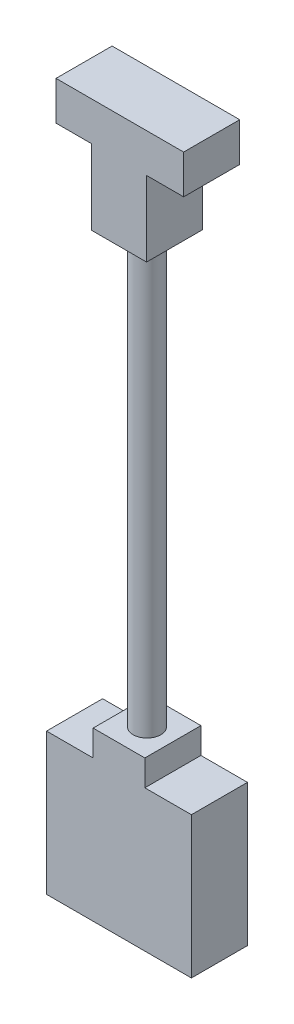
from build123d import *

# Parameters (mm, degrees)
BOSS_EXTRUDE1_DEPTH = 6.5
BOSS_EXTRUDE2_DEPTH = 6.5
SKETCH2_R           = 1.6
BOSS_EXTRUDE3_DEPTH = 55


with BuildPart() as part:
    # Sketch1 → Boss-Extrude1 (new body)
    with BuildSketch(Plane.XY):
        Polygon((9.277156847, 35.75), (13.377156847, 35.75), (13.377156847, 27.05), (19.777156847, 27.05), (19.777156847, 35.75), (24.077156847, 35.75), (24.077156847, 40.25), (9.277156847, 40.25), align=None)
    extrude(amount=BOSS_EXTRUDE1_DEPTH)



with BuildPart() as body_2:
    # Sketch1_6 → Boss-Extrude2 (new body)
    with BuildSketch(Plane.XY):
        Polygon((8.177156847, -42.25), (24.977156847, -42.25), (24.977156847, -25.85), (19.577156847, -25.85), (19.577156847, -22.85), (13.577156847, -22.85), (13.577156847, -25.85), (8.177156847, -25.85), align=None)
    extrude(amount=BOSS_EXTRUDE2_DEPTH)


with BuildPart() as part_1:
    add(part.part)

    add(body_2.part)  # Boss-Extrude3 merges body 2
    # Sketch2 → Boss-Extrude3 (add)
    with BuildSketch(Plane.XZ.offset(-27.05)):
        with Locations((16.577156847, 3.25)):
            Circle(SKETCH2_R)
    extrude(amount=BOSS_EXTRUDE3_DEPTH)


solid = part_1.part
